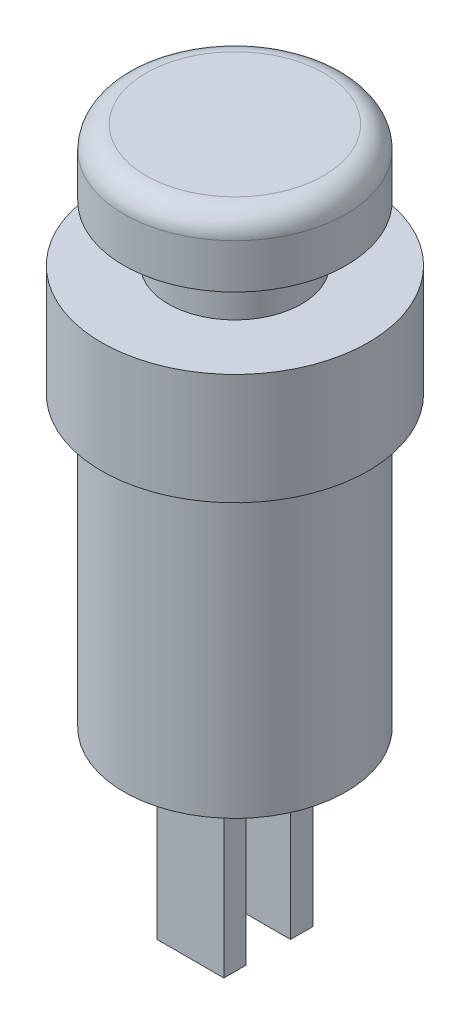
from build123d import *

# Parameters (mm, degrees)
ESQUISSE3_W        = 3
ESQUISSE3_H        = 1
BOSS_EXTRU_1_DEPTH = 8


with BuildPart() as part:
    # Esquisse1 → Révolution1 (revolve)
    with BuildSketch(Plane.XY):
        Polygon((0, 0), (-5, 0), (-5, 13), (-6, 13), (-6, 18), (-3, 18), (-3, 20.5), (0, 20.5), align=None)
    revolve(axis=Axis((0, 0, 0), (0, 1, 0)))

    # Esquisse2 → Révolution2 (revolve)
    with BuildSketch(Plane.XY):
        with BuildLine():
            Line((0, 20.5), (-5, 20.5))
            Line((-5, 20.5), (-5, 22.5))
            ThreePointArc((-5, 22.5), (-4.707106781, 23.207106781), (-4, 23.5))
            Line((-4, 23.5), (0, 23.5))
            Line((0, 23.5), (0, 20.5))
        make_face()
    revolve(axis=Axis((0, 20.5, 0), (0, 1, 0)))

    # Esquisse3 → Boss.-Extru.1 (add)
    with BuildSketch(Plane.XZ):
        with Locations((0, -1.5)):
            Rectangle(ESQUISSE3_W, ESQUISSE3_H)
        with Locations((0, 1.5)):
            Rectangle(ESQUISSE3_W, ESQUISSE3_H)
    extrude(amount=BOSS_EXTRU_1_DEPTH)


solid = part.part
